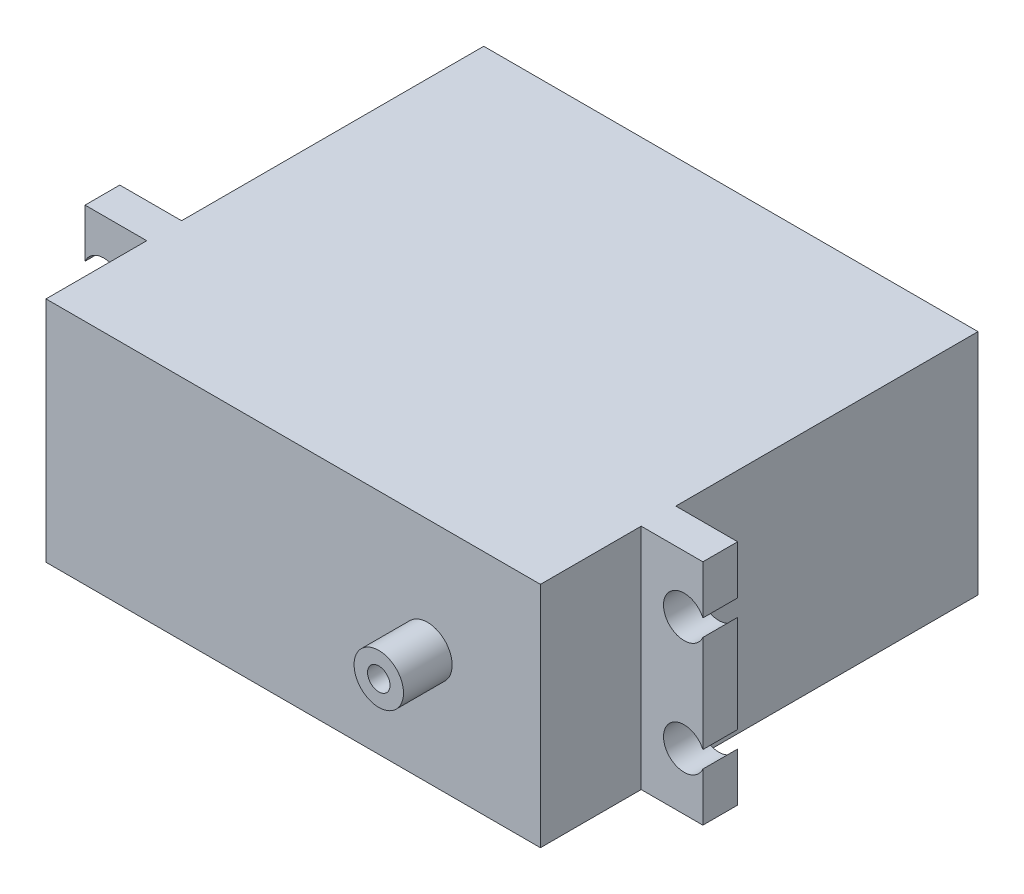
from build123d import *

# Parameters (mm, degrees)
SKETCH_1_W       = 66.04
SKETCH_1_H       = 30.48
EXTRUDE_1_DEPTH  = 40.3754
EXTRUDE_11_DEPTH = 4.64
SKETCH_3_W       = 66.06472
SKETCH_3_H       = 30.48
EXTRUDE_12_DEPTH = 13.462
SKETCH_5_R       = 3.302
SKETCH_5_R_2     = 1.5
EXTRUDE_13_DEPTH = 6.5


with BuildPart() as part:
    # 스케치1 → 보스-돌출1 (new body)
    with BuildSketch(Plane.XY):
        Rectangle(SKETCH_1_W, SKETCH_1_H)
    extrude(amount=EXTRUDE_1_DEPTH)

    # 스케치2 → 보스-돌출11 (add)
    with BuildSketch(Plane.XY.offset(40.3754)):
        with BuildLine():
            Line((41.275, -8.74168445), (41.275, -15.24))
            Line((41.275, -15.24), (-41.275, -15.24))
            Line((-41.275, -15.24), (-41.275, -8.74168445))
            ThreePointArc((-41.275, -8.74168445), (-36.01612, -7.61562), (-41.275, -6.48955555))
            Line((-41.275, -6.48955555), (-41.275, 6.48955555))
            ThreePointArc((-41.275, 6.48955555), (-36.01612, 7.61562), (-41.275, 8.74168445))
            Line((-41.275, 8.74168445), (-41.275, 15.24))
            Line((-41.275, 15.24), (41.275, 15.24))
            Line((41.275, 15.24), (41.275, 8.74168445))
            ThreePointArc((41.275, 8.74168445), (36.01612, 7.61562), (41.275, 6.48955555))
            Line((41.275, 6.48955555), (41.275, -6.48955555))
            ThreePointArc((41.275, -6.48955555), (36.01612, -7.61562), (41.275, -8.74168445))
        make_face()
    extrude(amount=EXTRUDE_11_DEPTH)

    # 스케치3 → 보스-돌출12 (add)
    with BuildSketch(Plane.XY.offset(45.0154)):
        Rectangle(SKETCH_3_W, SKETCH_3_H)
    extrude(amount=EXTRUDE_12_DEPTH)

    # 스케치5 → 보스-돌출13 (add)
    with BuildSketch(Plane.XY.offset(58.4774)):
        with Locations((17.9325, 0)):
            Circle(SKETCH_5_R)
        with Locations((17.9325, 0)):
            Circle(SKETCH_5_R_2, mode=Mode.SUBTRACT)
    extrude(amount=EXTRUDE_13_DEPTH)


solid = part.part
